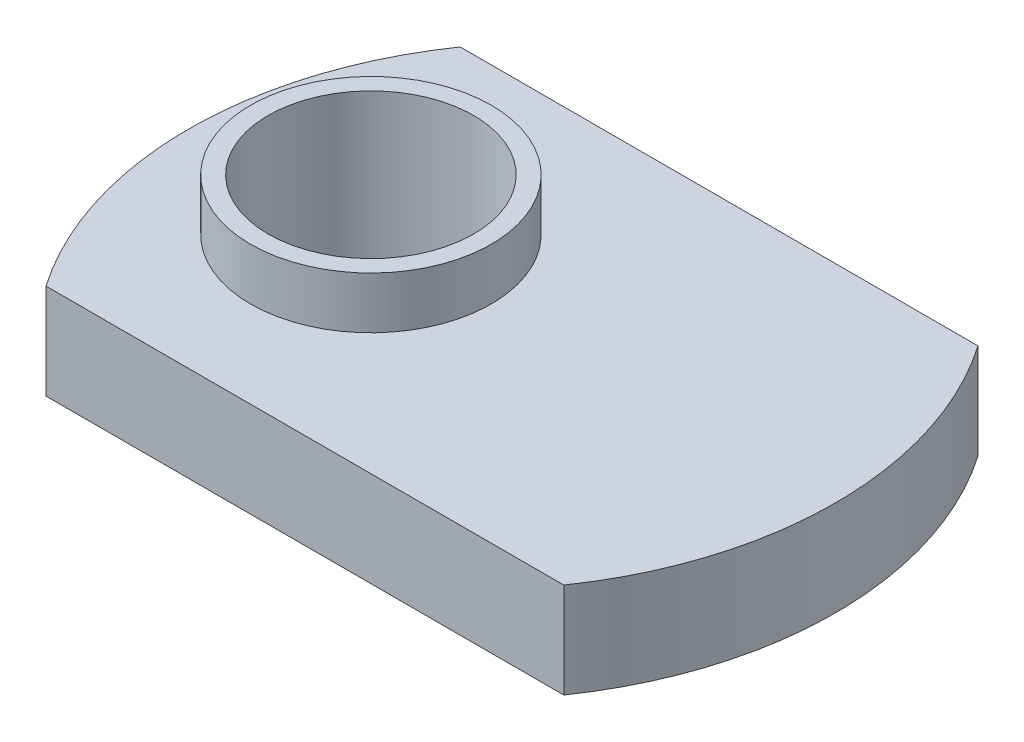
from build123d import *

# Parameters (mm, degrees)
SKETCH2_R           = 3.96875
BOSS_EXTRUDE1_DEPTH = 3.68
SKETCH3_R           = 4.65
SKETCH3_R_2         = 3.96875
BOSS_EXTRUDE2_DEPTH = 2


with BuildPart() as part:
    # Sketch2 → Boss-Extrude1 (new body)
    with BuildSketch(Plane(origin=(0, 0, 0), x_dir=(1, 0, 0), z_dir=(0, 1, 0))):
        with BuildLine():
            Line((0, 0), (20, 0))
            ThreePointArc((20, 0), (22.5, 8), (20, 16))
            Line((20, 16), (0, 16))
            ThreePointArc((0, 16), (-2.5, 8), (0, 0))
        make_face()
        with Locations((4.55, 8)):
            Circle(SKETCH2_R, mode=Mode.SUBTRACT)
    extrude(amount=BOSS_EXTRUDE1_DEPTH)

    # Sketch3 → Boss-Extrude2 (add)
    with BuildSketch(Plane(origin=(0, 3.68, 0), x_dir=(1, 0, 0), z_dir=(0, 1, 0))):
        with Locations((4.55, 8)):
            Circle(SKETCH3_R)
        with Locations((4.55, 8)):
            Circle(SKETCH3_R_2, mode=Mode.SUBTRACT)
    extrude(amount=BOSS_EXTRUDE2_DEPTH)


solid = part.part
